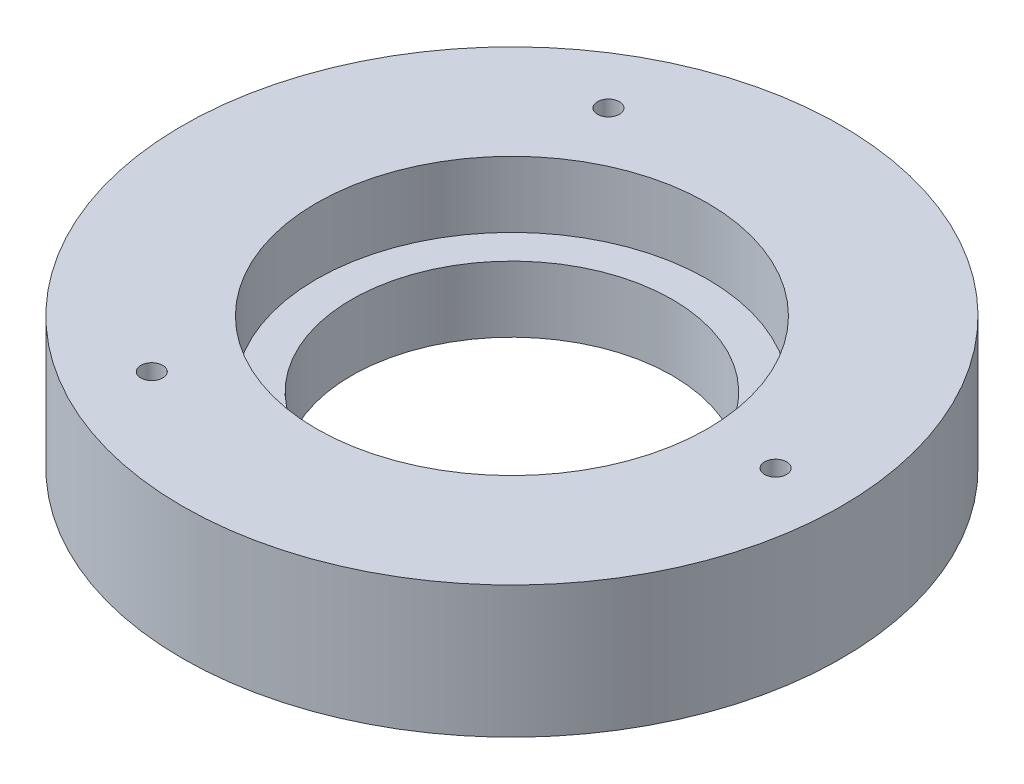
from build123d import *

# Parameters (mm, degrees)
SKETCH1_R           = 95.25
BOSS_EXTRUDE1_DEPTH = 19.05
SKETCH2_R           = 56.515
CUT_EXTRUDE1_DEPTH  = 19.05
SKETCH3_R           = 46.355
CUT_EXTRUDE2_DEPTH  = 19.05
SKETCH5_R           = 3.175
CUT_EXTRUDE3_DEPTH  = 38.1
CIRPATTERN1_COUNT   = 3
SKETCH6_R           = 3.175
CUT_EXTRUDE4_DEPTH  = 19.05
CIRPATTERN2_COUNT   = 3


with BuildPart() as part:
    # Sketch1 → Boss-Extrude1 (new body, symmetric)
    with BuildSketch(Plane(origin=(0, 0, 0), x_dir=(1, 0, 0), z_dir=(0, 1, 0))):
        Circle(SKETCH1_R)
    extrude(amount=BOSS_EXTRUDE1_DEPTH, both=True)

    # Sketch2 → Cut-Extrude1 (cut)
    with BuildSketch(Plane(origin=(0, 19.05, 0), x_dir=(-1, 0, 0), z_dir=(0, 1, 0))):
        Circle(SKETCH2_R)
    extrude(amount=-CUT_EXTRUDE1_DEPTH, mode=Mode.SUBTRACT)

    # Sketch3 → Cut-Extrude2 (cut)
    with BuildSketch(Plane.XZ.offset(19.05)):
        Circle(SKETCH3_R)
    extrude(amount=-CUT_EXTRUDE2_DEPTH, mode=Mode.SUBTRACT)

    # Sketch5 → Cut-Extrude3 (cut)
    with BuildSketch(Plane(origin=(0, 19.05, 0), x_dir=(-1, 0, 0), z_dir=(0, 1, 0))):
        with Locations((-76.2, 0)):
            Circle(SKETCH5_R)
    cut_extrude3 = extrude(amount=-CUT_EXTRUDE3_DEPTH, mode=Mode.SUBTRACT)

    # CirPattern1: Cut-Extrude3 ×3 about axis
    cirpattern1_axis = Axis((0, 0, 0), (0, 1, 0))
    for i in range(1, CIRPATTERN1_COUNT):
        add(cut_extrude3.rotate(cirpattern1_axis, i * 360 / CIRPATTERN1_COUNT), mode=Mode.SUBTRACT)

    # Sketch6 → Cut-Extrude4 (cut)
    with BuildSketch(Plane.XZ.offset(19.05)):
        with Locations((44.7675, 77.539584528)):
            Circle(SKETCH6_R)
    cut_extrude4 = extrude(amount=-CUT_EXTRUDE4_DEPTH, mode=Mode.SUBTRACT)

    # CirPattern2: Cut-Extrude4 ×3 about axis
    cirpattern2_axis = Axis((0, 0, 0), (0, 1, 0))
    for i in range(1, CIRPATTERN2_COUNT):
        add(cut_extrude4.rotate(cirpattern2_axis, i * 360 / CIRPATTERN2_COUNT), mode=Mode.SUBTRACT)


solid = part.part
